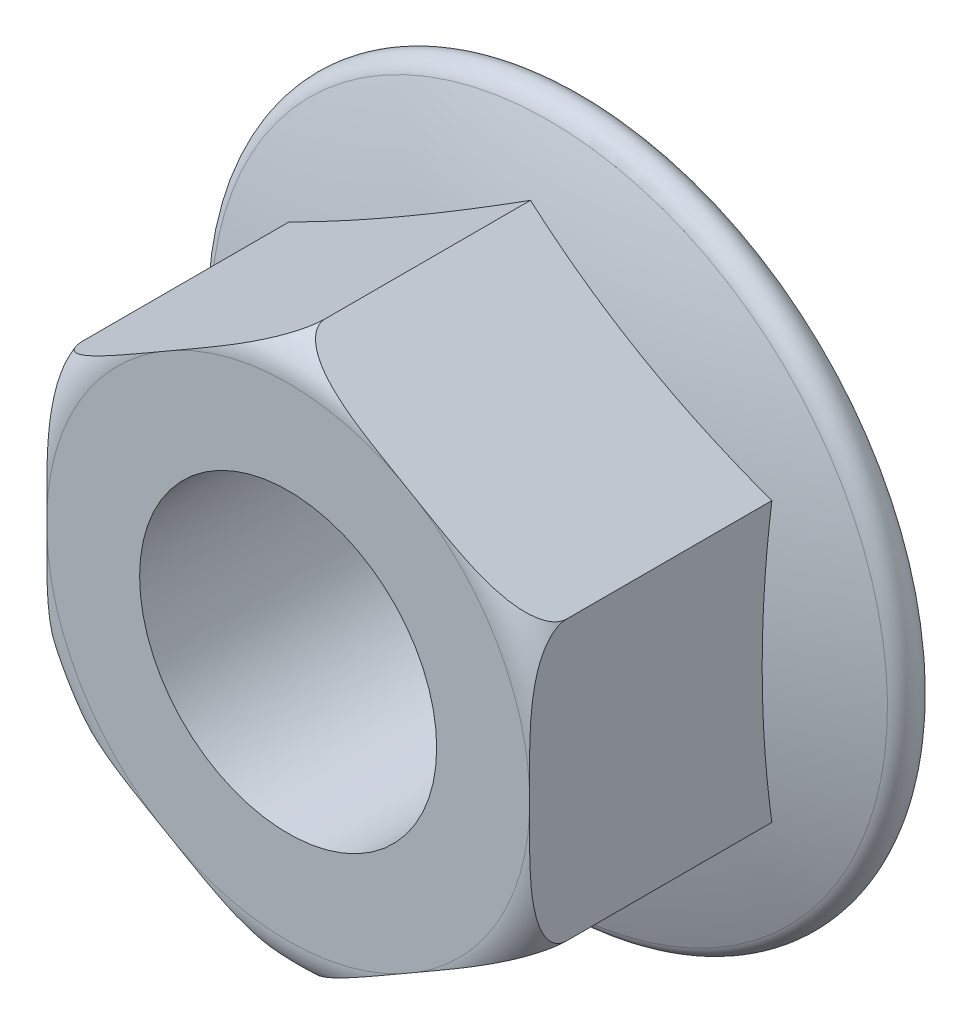
from build123d import *

# Parameters (mm, degrees)
HEAD_DEPTH         = 8
HOLE_SKETCH_R      = 4
THROUGH_HOLE_DEPTH = 9


with BuildPart() as part:
    # Head Sketch → Head (new body)
    with BuildSketch(Plane.XY):
        Polygon((0, 7.505553499), (6.5, 3.75277675), (6.5, -3.75277675), (0, -7.505553499), (-6.5, -3.75277675), (-6.5, 3.75277675), align=None)
    extrude(amount=HEAD_DEPTH)

    # Flange Sketch → Flange (revolve)
    with BuildSketch(Plane(origin=(0, 0, 0), x_dir=(-1, 0, 0), z_dir=(0, 1, 0))):
        with BuildLine():
            Line((-8.95, 0), (0, 0))
            Line((0, 0), (0, 2.5))
            ThreePointArc((0, 2.5), (-4.620060107, 2.115525306), (-9.11301873, 0.972678425))
            ThreePointArc((-9.11301873, 0.972678425), (-9.443122304, 0.417353804), (-8.95, 0))
        make_face()
    revolve(axis=Axis((0, 0, 1.843425858), (0, 0, 1)))

    # Sketch5 → Head Trim (revolve, cut)
    with BuildSketch(Plane(origin=(0, 0, 0), x_dir=(0, 0, -1), z_dir=(1, 0, 0))):
        with BuildLine():
            Line((-8, -6.505553499), (-8, -7.505553499))
            Line((-8, -7.505553499), (-7, -7.505553499))
            ThreePointArc((-7, -7.505553499), (-7.707106781, -7.212660281), (-8, -6.505553499))
        make_face()
    revolve(axis=Axis((0, 0, 15.085599173), (0, 0, -1)), mode=Mode.SUBTRACT)

    # Hole Sketch → Through Hole (cut, through all)
    with BuildSketch(Plane.XY.offset(8)):
        Circle(HOLE_SKETCH_R)
    extrude(amount=-THROUGH_HOLE_DEPTH, mode=Mode.SUBTRACT)


solid = part.part
